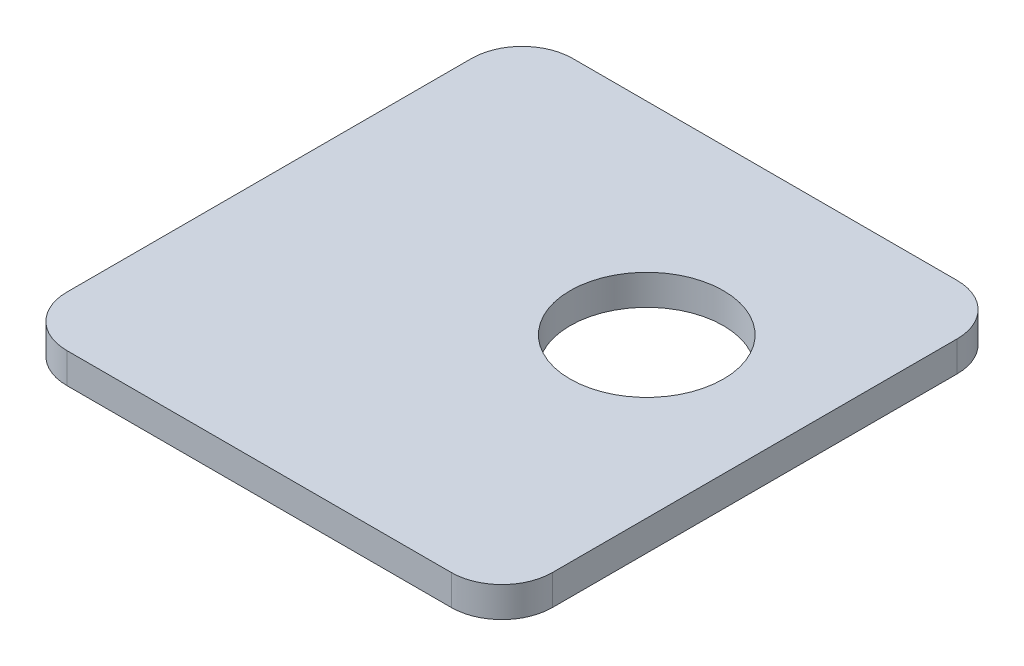
from build123d import *

# Parameters (mm, degrees)
SKETCH1_R           = 7.575
BOSS_EXTRUDE1_DEPTH = 3


with BuildPart() as part:
    # Sketch1 → Boss-Extrude1 (new body)
    with BuildSketch(Plane(origin=(0, 0, 0), x_dir=(1, 0, 0), z_dir=(0, 1, 0))):
        with BuildLine():
            Line((-19.42229117, 29.206654834), (18.57770883, 29.206654834))
            ThreePointArc((18.57770883, 29.206654834), (22.113242736, 27.74218874), (23.57770883, 24.206654834))
            Line((23.57770883, 24.206654834), (23.57770883, -15.793345166))
            ThreePointArc((23.57770883, -15.793345166), (22.113242736, -19.328879072), (18.57770883, -20.793345166))
            Line((18.57770883, -20.793345166), (-19.42229117, -20.793345166))
            ThreePointArc((-19.42229117, -20.793345166), (-22.957825076, -19.328879072), (-24.42229117, -15.793345166))
            Line((-24.42229117, -15.793345166), (-24.42229117, 24.206654834))
            ThreePointArc((-24.42229117, 24.206654834), (-22.957825076, 27.74218874), (-19.42229117, 29.206654834))
        make_face()
        with Locations((7.89472563, 9.208291295)):
            Circle(SKETCH1_R, mode=Mode.SUBTRACT)
    extrude(amount=BOSS_EXTRUDE1_DEPTH)


solid = part.part
